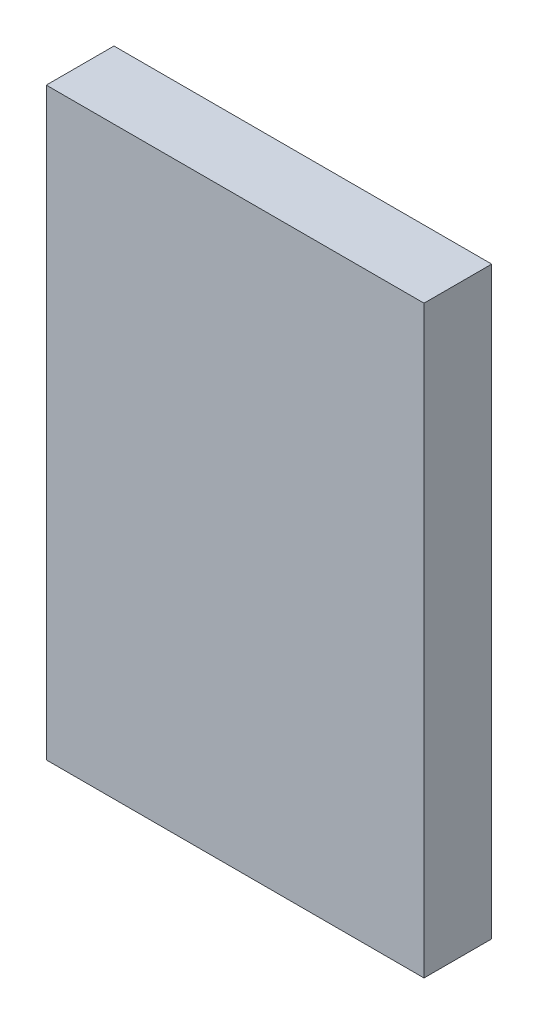
from build123d import *

# Parameters (mm, degrees)
EXTRUDE_1_DEPTH = 9.5
EXTRUDE_2_DEPTH = 5.5


with BuildPart() as part:
    # ｽｹｯﾁ1 → ﾎﾞｽ - 押し出し1 (new body)
    with BuildSketch(Plane.XY):
        Polygon((0, 82), (0, 68.75), (0, 67.25), (0, 14.75), (0, 13.25), (0, 0), (7.25, 0), (8.75, 0), (25.75, 0), (27.25, 0), (44.25, 0), (45.75, 0), (53, 0), (53, 82), align=None)
    extrude(amount=EXTRUDE_1_DEPTH)

    # ｽｹｯﾁ1<3> → ﾎﾞｽ - 押し出し2 (add)
    with BuildSketch(Plane.XY):
        with BuildLine():
            Line((0, 68.75), (-0.75, 68.75))
            ThreePointArc((-0.75, 68.75), (-1.5, 68), (-0.75, 67.25))
            Line((-0.75, 67.25), (0, 67.25))
            Line((0, 67.25), (0, 68.75))
        make_face()
        with BuildLine():
            Line((0, 13.25), (0, 14.75))
            Line((0, 14.75), (-0.75, 14.75))
            ThreePointArc((-0.75, 14.75), (-1.5, 14), (-0.75, 13.25))
            Line((-0.75, 13.25), (0, 13.25))
        make_face()
        with BuildLine():
            Line((45.75, -0.75), (45.75, 0))
            Line((45.75, 0), (44.25, 0))
            Line((44.25, 0), (44.25, -0.75))
            ThreePointArc((44.25, -0.75), (45, -1.5), (45.75, -0.75))
        make_face()
        with BuildLine():
            Line((8.75, 0), (7.25, 0))
            Line((7.25, 0), (7.25, -0.75))
            ThreePointArc((7.25, -0.75), (8, -1.5), (8.75, -0.75))
            Line((8.75, -0.75), (8.75, 0))
        make_face()
        with BuildLine():
            Line((27.25, -0.75), (27.25, 0))
            Line((27.25, 0), (25.75, 0))
            Line((25.75, 0), (25.75, -0.75))
            ThreePointArc((25.75, -0.75), (26.5, -1.5), (27.25, -0.75))
        make_face()
    extrude(amount=EXTRUDE_2_DEPTH)


solid = part.part
